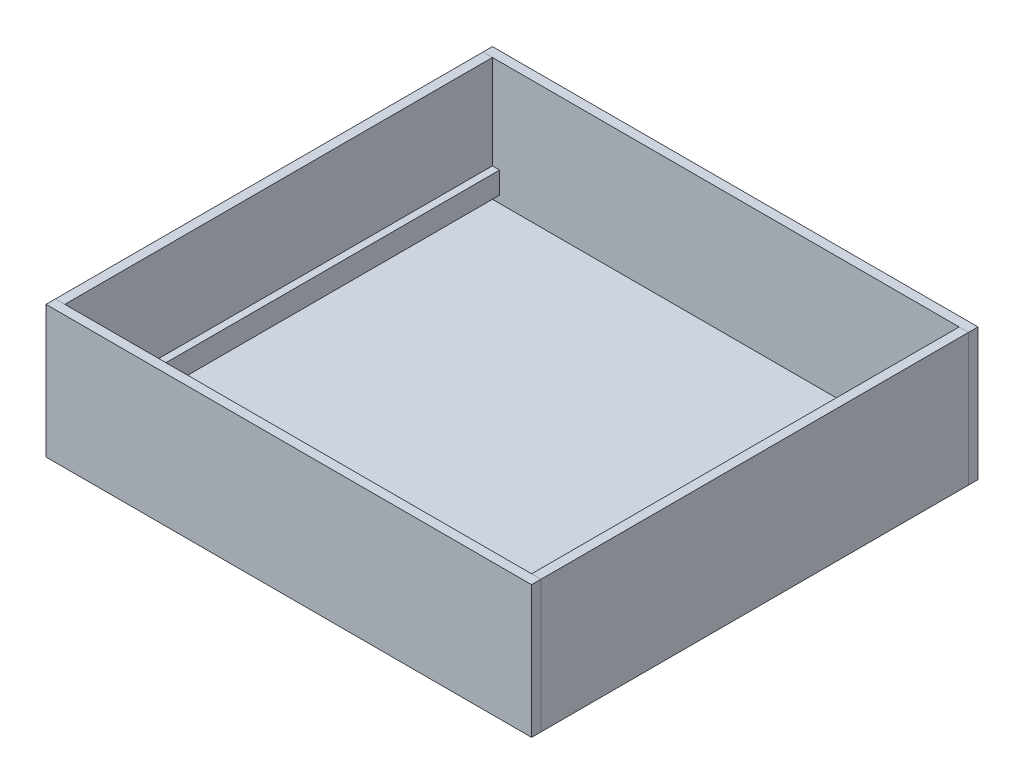
from build123d import *

# Parameters (mm, degrees)
SKETCH1_W             = 16.51
SKETCH1_H             = 231.775
BOSS_EXTRUDE1_DEPTH   = 749.3
BOSS_EXTRUDE1_2_DEPTH = 749.3
SKETCH1_3_W           = 817.88
SKETCH1_3_H           = 16.51
BOSS_EXTRUDE2_DEPTH   = 749.3
SKETCH2_W             = 850.9
SKETCH2_H             = 231.775
BOSS_EXTRUDE3_DEPTH   = 16.51
SKETCH3_W             = 12.7
SKETCH3_H             = 38.1
BOSS_EXTRUDE4_DEPTH   = 749.3
SKETCH7_R             = 3.7703125
CUT_EXTRUDE2_DEPTH    = 12.7
SKETCH15_W            = 850.9
SKETCH15_H            = 231.775
BOSS_EXTRUDE11_DEPTH  = 16.51


with BuildPart() as part:
    # Sketch1 → Boss-Extrude1 (new body)
    with BuildSketch(Plane.XY):
        with Locations((-417.195, 115.8875)):
            Rectangle(SKETCH1_W, SKETCH1_H)
    extrude(amount=-BOSS_EXTRUDE1_DEPTH)


with BuildPart() as body_2:
    # Sketch1 → Boss-Extrude1 2 (new body)
    with BuildSketch(Plane.XY):
        with Locations((417.195, 115.8875)):
            Rectangle(SKETCH1_W, SKETCH1_H)
    extrude(amount=-BOSS_EXTRUDE1_2_DEPTH)


with BuildPart() as body_3:
    # Sketch1_3 → Boss-Extrude2 (new body)
    with BuildSketch(Plane.XY):
        with Locations((0, 8.255)):
            Rectangle(SKETCH1_3_W, SKETCH1_3_H)
    extrude(amount=-BOSS_EXTRUDE2_DEPTH)


with BuildPart() as body_4:
    # Sketch2 → Boss-Extrude3 (new body)
    with BuildSketch(Plane(origin=(0, 0, -749.3), x_dir=(-1, 0, 0), z_dir=(0, 0, -1))):
        with Locations((0, 115.8875)):
            Rectangle(SKETCH2_W, SKETCH2_H)
    extrude(amount=BOSS_EXTRUDE3_DEPTH)


with BuildPart() as body_5:
    # Sketch3 → Boss-Extrude4 (new body)
    with BuildSketch(Plane.XY):
        with Locations((-402.59, 48.26)):
            Rectangle(SKETCH3_W, SKETCH3_H)
    extrude(amount=-BOSS_EXTRUDE4_DEPTH)


with BuildPart() as body_6:
    # Mirror1: mirrored copy
    add(body_5.part.mirror(Plane(origin=(0, 0, 0), x_dir=(0, 0, 1), z_dir=(1, 0, 0))))


with BuildPart() as cut_extrude2_tool:
    # Sketch7 → Cut-Extrude2 (new body)
    with BuildSketch(Plane.XY):
        with Locations((-415.925, 200.025)):
            Circle(SKETCH7_R)
        with Locations((415.925, 200.025)):
            Circle(SKETCH7_R)
    extrude(amount=-CUT_EXTRUDE2_DEPTH)


with BuildPart() as part_1:
    add(part.part)

    # Cut-Extrude2: cut by cut_extrude2_tool
    add(cut_extrude2_tool.part, mode=Mode.SUBTRACT)


with BuildPart() as body_2_1:
    add(body_2.part)

    # Cut-Extrude2: cut by cut_extrude2_tool
    add(cut_extrude2_tool.part, mode=Mode.SUBTRACT)


with BuildPart() as body_7:
    # Sketch15 → Boss-Extrude11 (new body)
    with BuildSketch(Plane.XY):
        with Locations((0, 115.8875)):
            Rectangle(SKETCH15_W, SKETCH15_H)
    extrude(amount=BOSS_EXTRUDE11_DEPTH)


solid = Compound([body_3.part, body_4.part, body_5.part, body_6.part, part_1.part, body_2_1.part, body_7.part])
